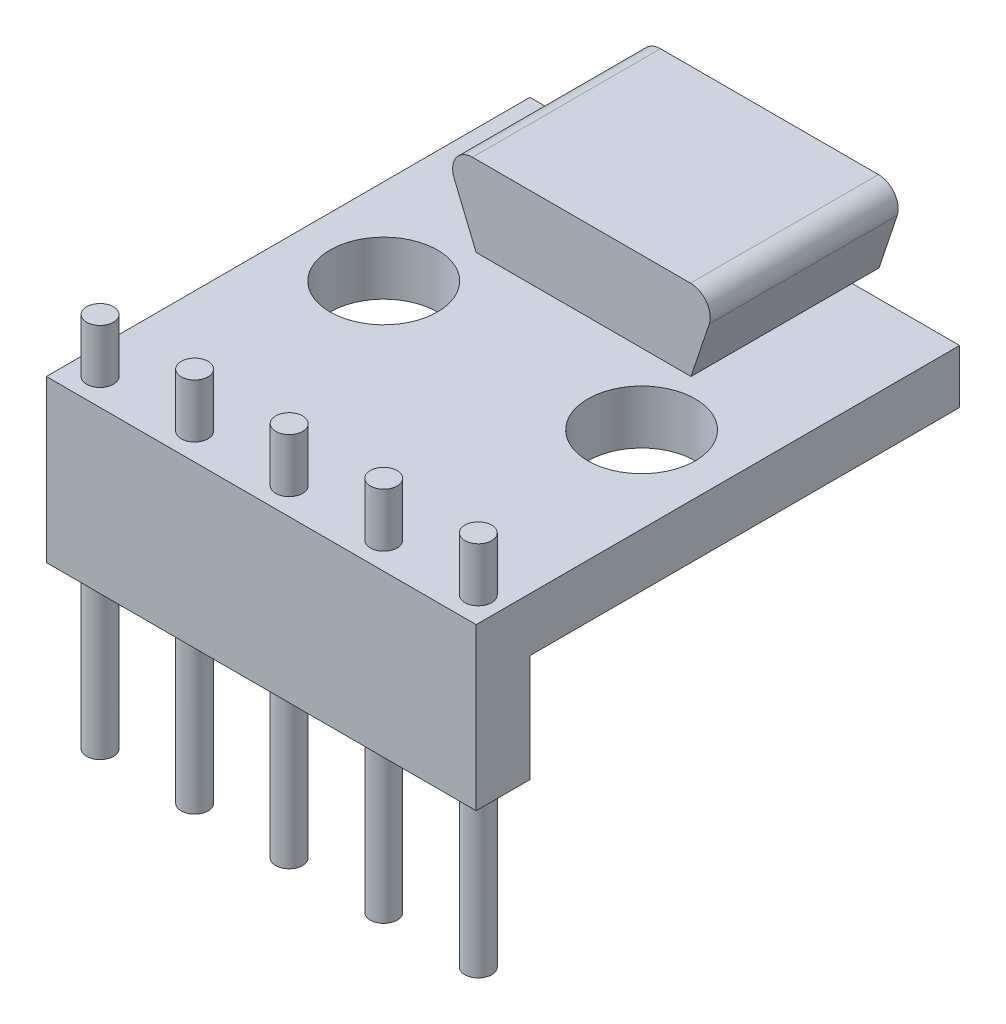
from build123d import *

# Parameters (mm, degrees)
SKETCH1_W                = 12.7
SKETCH1_H                = 14.2875
SKETCH1_R                = 1.5875
BOSS_EXTRUDE1_DEPTH      = 1.5875
SKETCH2_W                = 12.7
SKETCH2_H                = 3.175
BOSS_EXTRUDE2_DEPTH      = 1.5875
SKETCH3_R                = 0.396875
CUT_EXTRUDE1_DEPTH       = 5.7625
SKETCH4_R                = 0.396875
BOSS_EXTRUDE3_DEPTH      = 1.5875
BOSS_EXTRUDE3_DEPTH_BACK = 9.525
BOSS_EXTRUDE5_DEPTH      = 0.79375
BOSS_EXTRUDE5_DEPTH_BACK = 4.7625


with BuildPart() as part:
    # Sketch1 → Boss-Extrude1 (new body)
    with BuildSketch(Plane(origin=(0, 0, 0), x_dir=(1, 0, 0), z_dir=(0, 1, 0))):
        with Locations((6.35, -7.14375)):
            Rectangle(SKETCH1_W, SKETCH1_H)
        with Locations((10.16, -6.858)):
            Circle(SKETCH1_R, mode=Mode.SUBTRACT)
        with Locations((2.54, -6.858)):
            Circle(SKETCH1_R, mode=Mode.SUBTRACT)
    extrude(amount=-BOSS_EXTRUDE1_DEPTH)

    # Sketch2 → Boss-Extrude2 (add)
    with BuildSketch(Plane.XY.offset(14.2875)):
        with Locations((6.35, -3.175)):
            Rectangle(SKETCH2_W, SKETCH2_H)
    extrude(amount=-BOSS_EXTRUDE2_DEPTH)

    # Sketch3 → Cut-Extrude1 (cut, through all)
    with BuildSketch(Plane(origin=(0, 0, 0), x_dir=(1, 0, 0), z_dir=(0, 1, 0))):
        with Locations((0.79375, -13.49375)):
            Circle(SKETCH3_R)
        with Locations((3.58775, -13.49375)):
            Circle(SKETCH3_R)
        with Locations((6.38175, -13.49375)):
            Circle(SKETCH3_R)
        with Locations((9.17575, -13.49375)):
            Circle(SKETCH3_R)
        with Locations((11.96975, -13.49375)):
            Circle(SKETCH3_R)
    extrude(amount=-CUT_EXTRUDE1_DEPTH, mode=Mode.SUBTRACT)

    # Sketch4 → Boss-Extrude3 (add, two sides)
    with BuildSketch(Plane(origin=(0, 0, 0), x_dir=(1, 0, 0), z_dir=(0, 1, 0))) as boss_extrude3_sk:
        with Locations((0.79375, -13.49375)):
            Circle(SKETCH4_R)
        with Locations((3.58775, -13.49375)):
            Circle(SKETCH4_R)
        with Locations((6.38175, -13.49375)):
            Circle(SKETCH4_R)
        with Locations((9.17575, -13.49375)):
            Circle(SKETCH4_R)
        with Locations((11.96975, -13.49375)):
            Circle(SKETCH4_R)
    extrude(amount=BOSS_EXTRUDE3_DEPTH)
    extrude(boss_extrude3_sk.sketch, amount=-BOSS_EXTRUDE3_DEPTH_BACK)

    # Sketch5 → Boss-Extrude5 (add, two sides)
    with BuildSketch(Plane(origin=(0, 0, 0), x_dir=(-1, 0, 0), z_dir=(0, 0, -1))) as boss_extrude5_sk:
        with BuildLine():
            Line((-9.525, 0), (-10.062267539, 1.611802618))
            ThreePointArc((-10.062267539, 1.611802618), (-9.981921487, 2.138477744), (-9.507681244, 2.38125))
            Line((-9.507681244, 2.38125), (-3.065174491, 2.38125))
            ThreePointArc((-3.065174491, 2.38125), (-2.579253026, 2.12165746), (-2.524890791, 1.573430586))
            Line((-2.524890791, 1.573430586), (-3.175, 0))
            Line((-3.175, 0), (-9.525, 0))
        make_face()
    extrude(amount=BOSS_EXTRUDE5_DEPTH)
    extrude(boss_extrude5_sk.sketch, amount=-BOSS_EXTRUDE5_DEPTH_BACK)


solid = part.part
